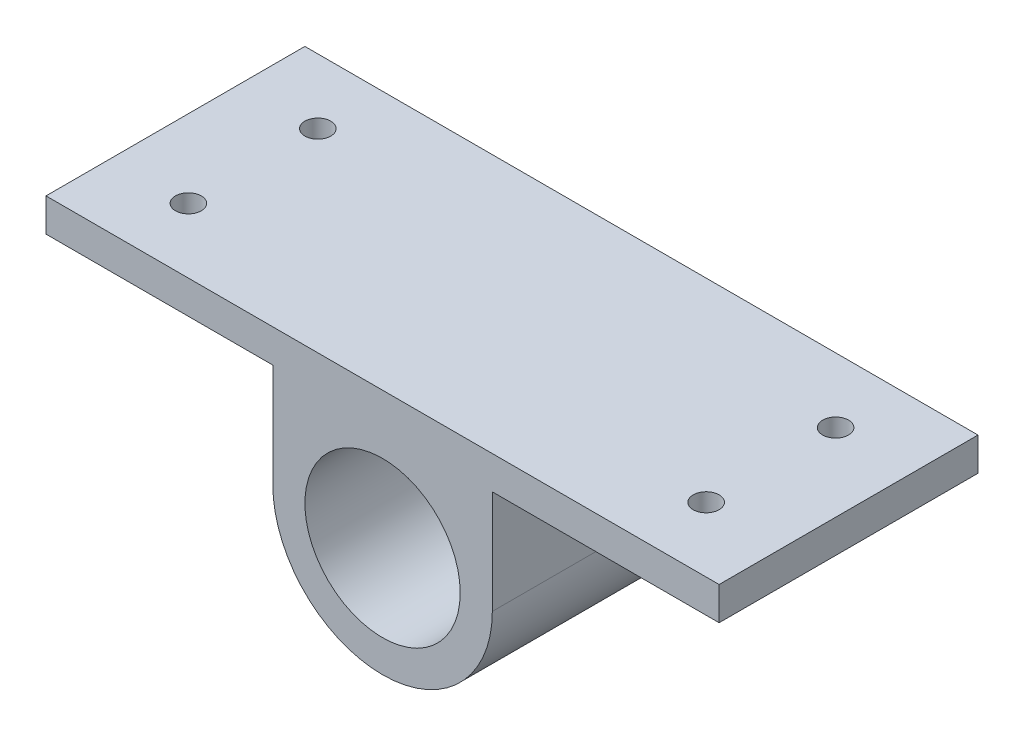
from build123d import *

# Parameters (mm, degrees)
SKETCH1_R           = 75
BOSS_EXTRUDE1_DEPTH = 250
SKETCH2_R           = 12.5
CUT_EXTRUDE1_DEPTH  = 250


with BuildPart() as part:
    # Sketch1 → Boss-Extrude1 (new body)
    with BuildSketch(Plane.XY):
        with BuildLine():
            Line((325, 0), (-325, 0))
            Line((-325, 0), (-325, -32))
            Line((-325, -32), (-106, -32))
            Line((-106, -32), (-106, -132))
            ThreePointArc((-106, -132), (0, -238), (106, -132))
            Line((106, -132), (106, -32))
            Line((106, -32), (325, -32))
            Line((325, -32), (325, 0))
        make_face()
        with Locations((0, -132)):
            Circle(SKETCH1_R, mode=Mode.SUBTRACT)
    extrude(amount=BOSS_EXTRUDE1_DEPTH)

    # Sketch2 → Cut-Extrude1 (cut)
    with BuildSketch(Plane(origin=(0, 0, 0), x_dir=(1, 0, 0), z_dir=(0, 1, 0))):
        with Locations(Location((-250, -187.5, 0), (0, 0, 180))):  # turned: the seam where the file's is
            Circle(SKETCH2_R)
        with Locations(Location((-250, -62.5, 0), (0, 0, 180))):  # turned: the seam where the file's is
            Circle(SKETCH2_R)
        with Locations(Location((250, -187.5, 0), (0, 0, 90))):  # turned: the seam where the file's is
            Circle(SKETCH2_R)
        with Locations(Location((250, -62.5, 0), (0, 0, 90))):  # turned: the seam where the file's is
            Circle(SKETCH2_R)
    extrude(amount=-CUT_EXTRUDE1_DEPTH, mode=Mode.SUBTRACT)


solid = part.part
